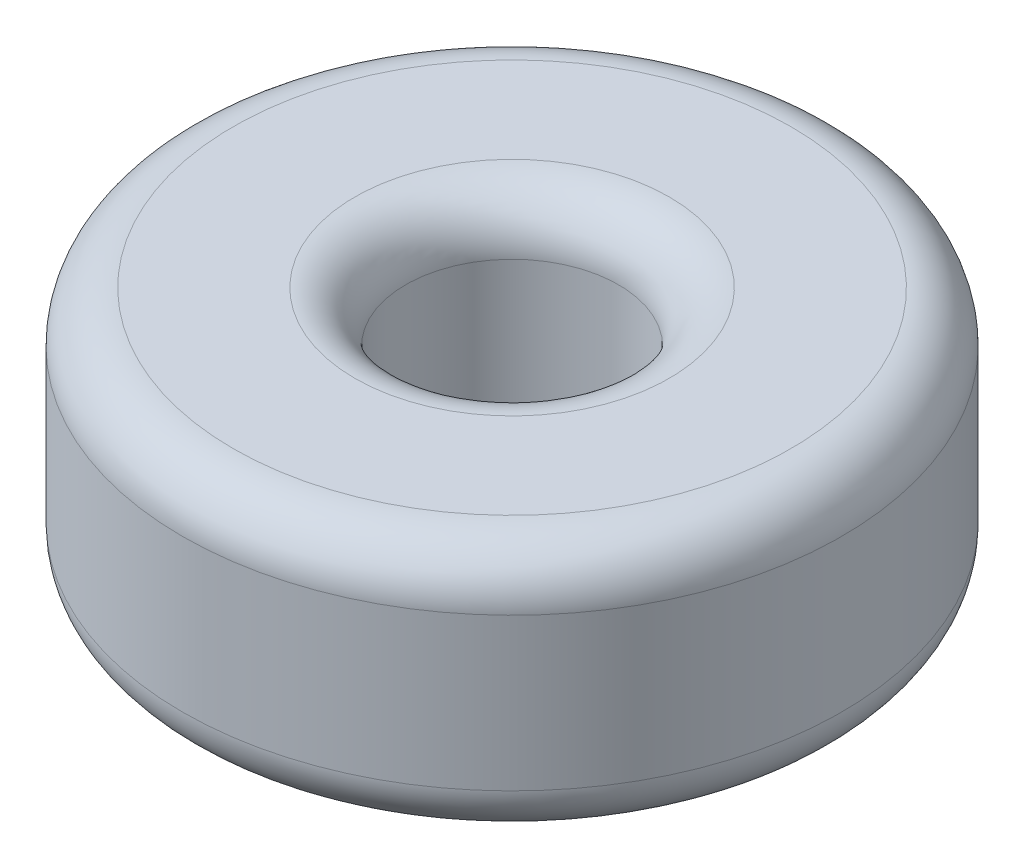
from build123d import *

# Parameters (mm, degrees)
SKETCH1_R           = 6.5
SKETCH1_R_2         = 2.1
BOSS_EXTRUDE1_DEPTH = 5
FILLET1_R           = 1


with BuildPart() as part:
    # Sketch1 → Boss-Extrude1 (new body)
    with BuildSketch(Plane(origin=(0, 0, 0), x_dir=(1, 0, 0), z_dir=(0, 1, 0))):
        Circle(SKETCH1_R)
        Circle(SKETCH1_R_2, mode=Mode.SUBTRACT)
    extrude(amount=BOSS_EXTRUDE1_DEPTH)

    # Fillet1
    fillet1_edges = [part.edges().sort_by_distance(p)[0] for p in [
        (-6.5, 0, 0),
        (-6.5, 5, 0),
        (-2.1, 0, 0),
        (-2.1, 5, 0),
    ]]
    fillet(fillet1_edges, radius=FILLET1_R)


solid = part.part
